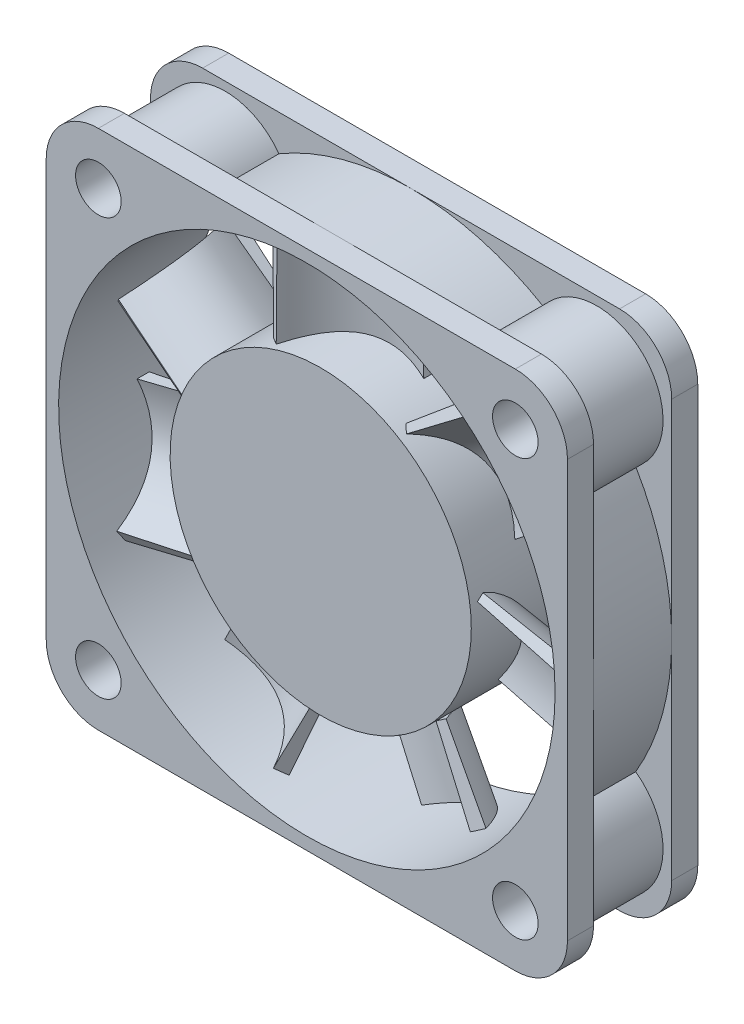
from build123d import *

# Parameters (mm, degrees)
SKETCH7_R           = 11.557
BOSS_EXTRUDE1_DEPTH = 3.937
CIRPATTERN1_COUNT   = 7
BOSS_EXTRUDE2_START = -5
SKETCH9_W           = 40
SKETCH9_H           = 40
BOSS_EXTRUDE2_DEPTH = 2
SKETCH10_R          = 19.05
BOSS_EXTRUDE5_DEPTH = 6
SKETCH11_W          = 40
SKETCH11_H          = 40
SKETCH11_R          = 19.05
BOSS_EXTRUDE6_DEPTH = 2
SKETCH12_R          = 1.75
CUT_EXTRUDE1_DEPTH  = 39.484211759
FILLET1_R           = 4


with BuildPart() as part:
    # Sketch5 → Loft2 section 0
    with BuildSketch(Plane(origin=(-2.380044301, 0, 3.909871942), x_dir=(-0.8541866934469932, 0, -0.5199664342417621), z_dir=(0.5199664342417621, 0, -0.8541866934469932))):
        Polygon((1.027518199, 0), (1.624418199, 0), (1.792058199, 6.563759566), (0.859878199, 6.563759566), align=None)
    # Sketch4 → Loft2 section 1
    with BuildSketch(Plane(origin=(0, 0, 0), x_dir=(0.4899150772114617, 0, 0.8717701630136738), z_dir=(-0.8717701630136738, 0, 0.4899150772114617))):
        Polygon((-0.644542879, 0), (0, 0), (0.143818561, 6.56432472), (-0.788361439, 6.56432472), align=None)
    # Sketch2 → Loft2 section 2
    with BuildSketch(Plane(origin=(4.691215528, 0, 0), x_dir=(0, 0, -1), z_dir=(1, 0, 0))):
        Polygon((0, 0), (0.5969, 0), (0.76454, 6.563759566), (-0.16764, 6.563759566), align=None)
    loft2 = loft()

    # Sketch7 → Boss-Extrude1 (add, symmetric)
    with BuildSketch(Plane.XY):
        with Locations((0.716739427, -10.852086837)):
            Circle(SKETCH7_R)
    extrude(amount=BOSS_EXTRUDE1_DEPTH, both=True)

    # CirPattern1: Loft2 ×7 about axis
    cirpattern1_axis = Axis((0.716739427, -10.852086837, 3.937), (0, 0, -1))
    for i in range(1, CIRPATTERN1_COUNT):
        add(loft2.rotate(cirpattern1_axis, i * 360 / CIRPATTERN1_COUNT))

    # Sketch9 → Boss-Extrude2 (add)
    with BuildSketch(Plane.XY.offset(BOSS_EXTRUDE2_START)):
        with Locations((0.716739427, -10.852086837)):
            Rectangle(SKETCH9_W, SKETCH9_H)
        with BuildLine():
            Line((0.716739427, 8.197913163), (-7.62, -2.848148761))
            ThreePointArc((-7.62, -2.848148761), (-10.833479864, -11.247919283), (-7.052485184, -19.407985267))
            Line((-7.052485184, -19.407985267), (-16.860679306, -18.196258041))
            ThreePointArc((-16.860679306, -18.196258041), (-15.139000251, -0.292824586), (0.716739427, 8.197913163))
        make_face(mode=Mode.SUBTRACT)
        with BuildLine():
            Line((3.145209961, 8.042489921), (-2.808273661, 0.154208258))
            ThreePointArc((-2.808273661, 0.154208258), (6.149048119, -0.651387289), (11.816722845, -7.634227747))
            Line((11.816722845, -7.634227747), (17.214523369, -20.377086837))
            ThreePointArc((17.214523369, -20.377086837), (17.78919862, -2.400244606), (3.145209961, 8.042489921))
        make_face(mode=Mode.SUBTRACT)
        with BuildLine():
            Line((15.865687626, -22.402492391), (12.010977125, -13.302483503))
            ThreePointArc((12.010977125, -13.302483503), (6.834650026, -20.65695394), (-2.046504564, -22.073884004))
            Line((-2.046504564, -22.073884004), (-15.781044515, -20.377086837))
            ThreePointArc((-15.781044515, -20.377086837), (-0.499980089, -29.863191319), (15.865687626, -22.402492391))
        make_face(mode=Mode.SUBTRACT)
    extrude(amount=BOSS_EXTRUDE2_DEPTH)

    # Sketch10 → Boss-Extrude5 (add)
    with BuildSketch(Plane.XY.offset(-3)):
        with BuildLine():
            ThreePointArc((-16.520507901, -0.709241845), (-19.283260573, -10.852086837), (-16.520507901, -20.99493183))
            ThreePointArc((-16.520507901, -20.99493183), (-17.131592787, -28.700419051), (-9.426105566, -28.089334165))
            ThreePointArc((-9.426105566, -28.089334165), (0.716739427, -30.852086837), (10.85958442, -28.089334165))
            ThreePointArc((10.85958442, -28.089334165), (18.565071641, -28.700419051), (17.953986755, -20.99493183))
            ThreePointArc((17.953986755, -20.99493183), (20.716739427, -10.852086837), (17.953986755, -0.709241845))
            ThreePointArc((17.953986755, -0.709241845), (18.565071641, 6.996245377), (10.85958442, 6.385160491))
            ThreePointArc((10.85958442, 6.385160491), (0.716739427, 9.147913163), (-9.426105566, 6.385160491))
            ThreePointArc((-9.426105566, 6.385160491), (-17.131592787, 6.996245377), (-16.520507901, -0.709241845))
        make_face()
        with Locations(Location((0.716739427, -10.852086837, 0), (0, 0, 202.67607585))):
            Circle(SKETCH10_R, mode=Mode.SUBTRACT)
    extrude(amount=BOSS_EXTRUDE5_DEPTH)

    # Sketch11 → Boss-Extrude6 (add)
    with BuildSketch(Plane.XY.offset(3)):
        with Locations((0.716739427, -10.852086837)):
            Rectangle(SKETCH11_W, SKETCH11_H)
        with Locations(Location((0.716739427, -10.852086837, 0), (0, 0, 202.67607585))):
            Circle(SKETCH11_R, mode=Mode.SUBTRACT)
    extrude(amount=BOSS_EXTRUDE6_DEPTH)

    # Sketch12 → Cut-Extrude1 (cut, through all)
    with BuildSketch(Plane.XY.offset(5)):
        with Locations((-15.283260573, 5.147913163)):
            Circle(SKETCH12_R)
        with Locations((16.716739427, 5.147913163)):
            Circle(SKETCH12_R)
        with Locations((16.716739427, -26.852086837)):
            Circle(SKETCH12_R)
        with Locations((-15.283260573, -26.852086837)):
            Circle(SKETCH12_R)
    extrude(amount=-CUT_EXTRUDE1_DEPTH, mode=Mode.SUBTRACT)

    # Fillet1
    fillet1_edges = [part.edges().sort_by_distance(p)[0] for p in [
        (20.716739427, -30.852086837, -4),
        (20.716739427, 9.147913163, -4),
        (-19.283260573, 9.147913163, -4),
        (-19.283260573, -30.852086837, -4),
        (20.716739427, -30.852086837, 4),
        (20.716739427, 9.147913163, 4),
        (-19.283260573, 9.147913163, 4),
        (-19.283260573, -30.852086837, 4),
    ]]
    fillet(fillet1_edges, radius=FILLET1_R)


solid = part.part
